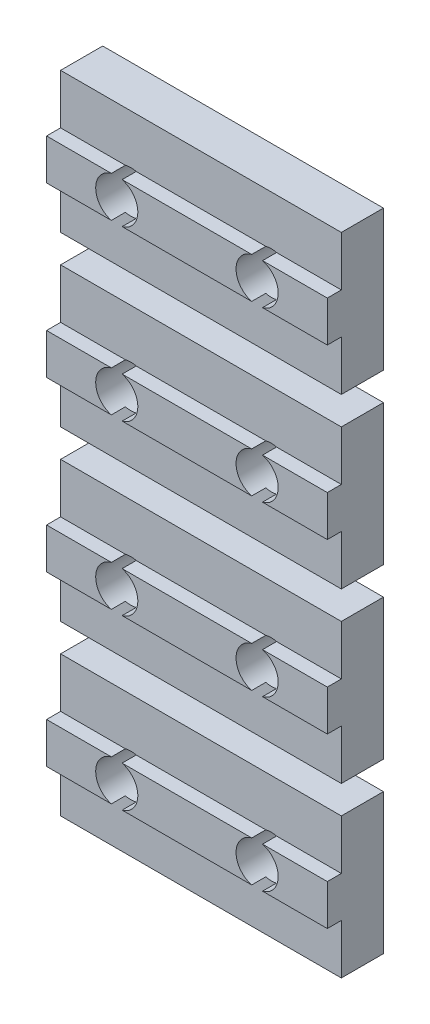
from build123d import *

# Parameters (mm, degrees)
ESQUISSE1_W      = 20
ESQUISSE1_H      = 10
MAIN_DEPTH       = 3
ESQUISSE2_W      = 20
ESQUISSE2_H      = 2.9
CENTRALFIX_DEPTH = 1
ESQUISSE3_R      = 1.5
HOLESFIX_DEPTH   = 5
LPATTERN1_COUNT  = 4
LPATTERN1_PITCH  = 12


with BuildPart() as part:
    # Esquisse1 → Main (new body)
    with BuildSketch(Plane.XY):
        with Locations((10, 5)):
            Rectangle(ESQUISSE1_W, ESQUISSE1_H)
    extrude(amount=MAIN_DEPTH)

    # Esquisse2 → CentralFix (add)
    with BuildSketch(Plane.XY.offset(3)):
        with Locations((10, 5)):
            Rectangle(ESQUISSE2_W, ESQUISSE2_H)
    extrude(amount=CENTRALFIX_DEPTH)

    # Esquisse3 → HolesFix (cut, through all)
    with BuildSketch(Plane(origin=(0, 0, 0), x_dir=(-1, 0, 0), z_dir=(0, 0, -1))):
        with Locations((-15, 5)):
            Circle(ESQUISSE3_R)
        with Locations((-5, 5)):
            Circle(ESQUISSE3_R)
    extrude(amount=-HOLESFIX_DEPTH, mode=Mode.SUBTRACT)


with BuildPart() as lpattern1_1:
    # LPattern1: pattern copy
    add(part.part.moved(Location(Vector(0, 1, 0) * (1 * LPATTERN1_PITCH))))


with BuildPart() as lpattern1_2:
    # LPattern1: pattern copy
    add(part.part.moved(Location(Vector(0, 1, 0) * (2 * LPATTERN1_PITCH))))


with BuildPart() as lpattern1_3:
    # LPattern1: pattern copy
    add(part.part.moved(Location(Vector(0, 1, 0) * (3 * LPATTERN1_PITCH))))


solid = Compound([part.part, lpattern1_1.part, lpattern1_2.part, lpattern1_3.part])
